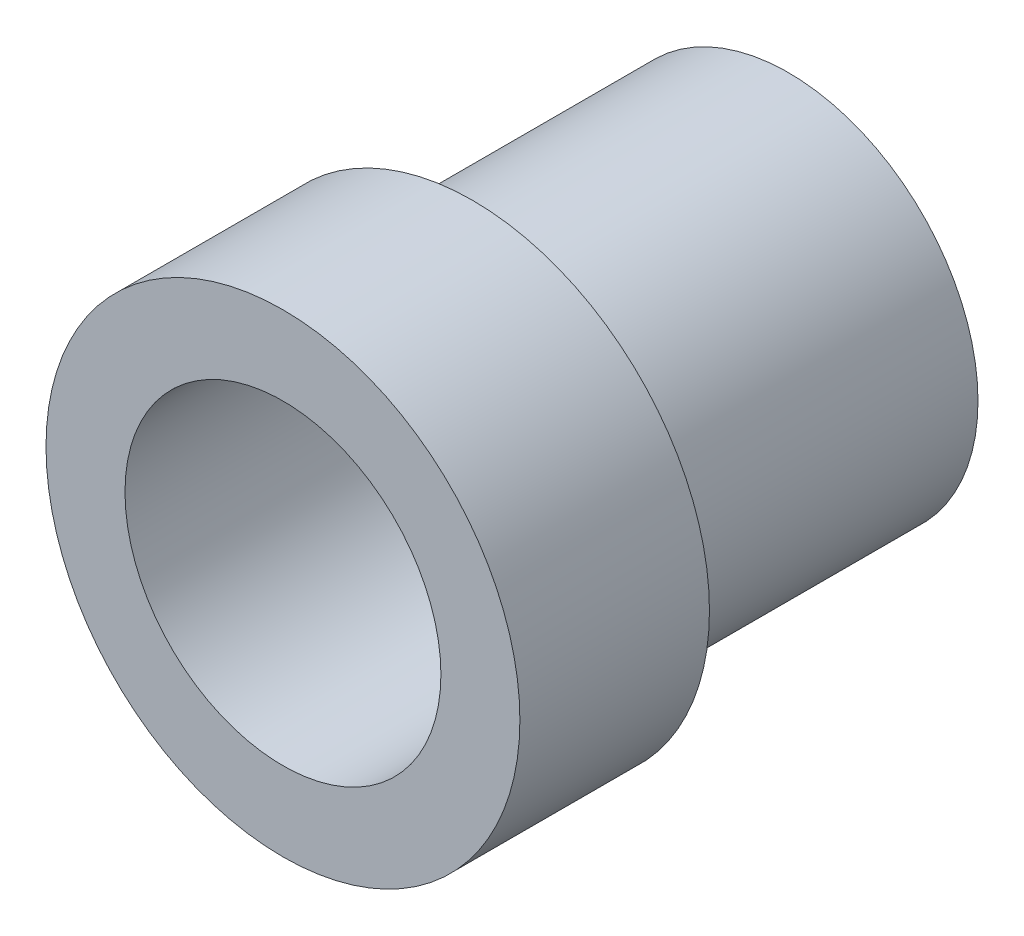
from build123d import *

# Parameters (mm, degrees)
SKETCH_1_R          = 6
EXTRUDE_1_DEPTH     = 10
SKETCH_2_R          = 7.5
EXTRUDE_2_DEPTH     = 6
SKETCH_3_R          = 5
CUT_EXTRUDE_1_DEPTH = 24


with BuildPart() as part:
    # 草图1 → 凸台-拉伸1 (new body)
    with BuildSketch(Plane.XY):
        Circle(SKETCH_1_R)
    extrude(amount=EXTRUDE_1_DEPTH)

    # 草图2 → 凸台-拉伸2 (add)
    with BuildSketch(Plane.XY.offset(10)):
        Circle(SKETCH_2_R)
    extrude(amount=EXTRUDE_2_DEPTH)

    # 草图3 → 切除-拉伸1 (cut)
    with BuildSketch(Plane(origin=(0, 0, 0), x_dir=(-1, 0, 0), z_dir=(0, 0, -1))):
        Circle(SKETCH_3_R)
    extrude(amount=-CUT_EXTRUDE_1_DEPTH, mode=Mode.SUBTRACT)


solid = part.part
